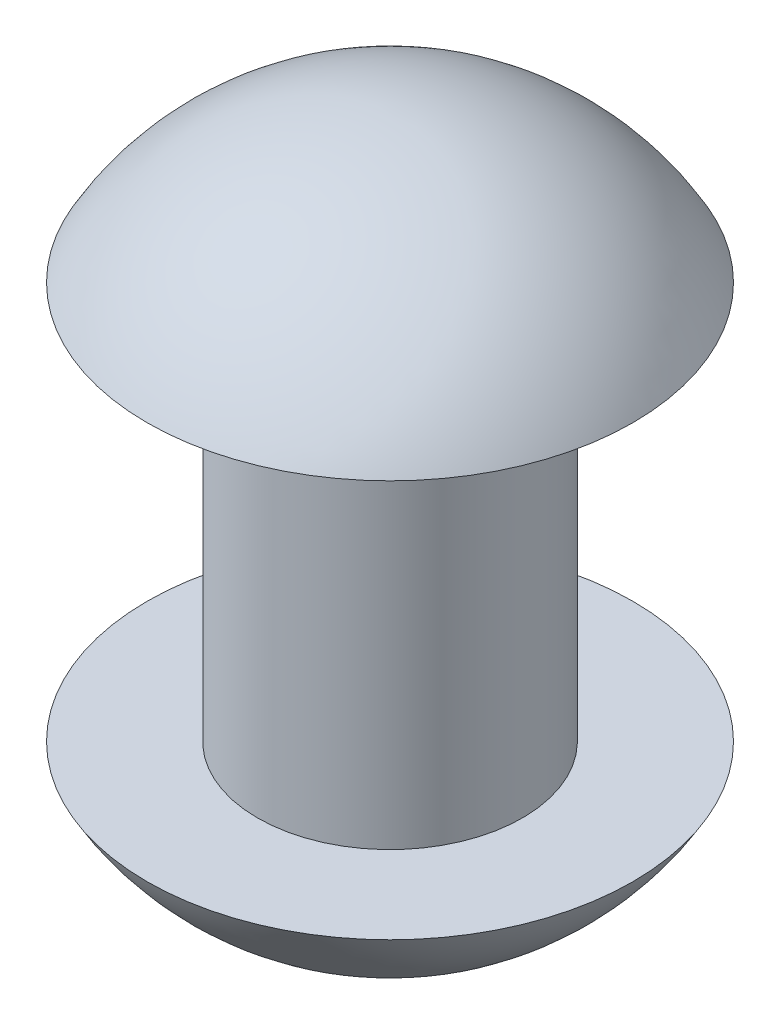
from build123d import *


with BuildPart() as part:
    # Sketch1 → Revolve1 (revolve)
    with BuildSketch(Plane.XY):
        with BuildLine():
            Line((-0.12, 0), (-0.12, 0.36))
            Line((-0.12, 0.36), (-0.22, 0.36))
            ThreePointArc((-0.22, 0.36), (-0.127502863, 0.454336227), (0, 0.488949292))
            Line((0, 0.488949292), (0, -0.128949292))
            ThreePointArc((0, -0.128949292), (-0.127502863, -0.094336227), (-0.22, 0))
            Line((-0.22, 0), (-0.12, 0))
        make_face()
    revolve(axis=Axis((0, 0.488949292, 0), (0, -1, 0)))


solid = part.part
